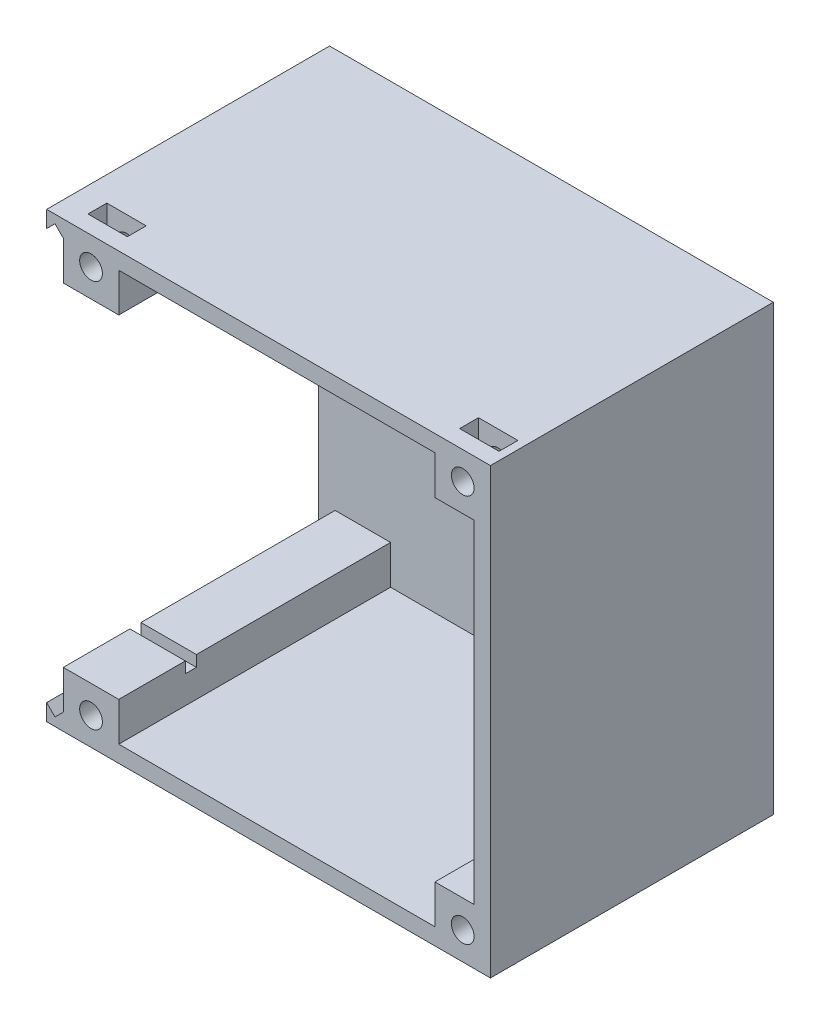
from build123d import *

# Parameters (mm, degrees)
ESQUISSE3_W             = 80
ESQUISSE3_H             = 80
BOSS_EXTRU_1_DEPTH      = 2
BOSS_EXTRU_2_DEPTH      = 49
ESQUISSE7_R             = 2.05
ENL_V_MAT_EXTRU_1_DEPTH = 30
ESQUISSE8_W             = 7.1
ESQUISSE8_H             = 3.4
ENL_V_MAT_EXTRU_2_DEPTH = 9
ESQUISSE9_W             = 7.1
ESQUISSE9_H             = 3.4
ENL_V_MAT_EXTRU_3_DEPTH = 9
ESQUISSE10_W            = 2
ESQUISSE10_H            = 2
ENL_V_MAT_EXTRU_4_DEPTH = 74


with BuildPart() as part:
    # Esquisse3 → Boss.-Extru.1 (new body)
    with BuildSketch(Plane.XY):
        with Locations((40, 40)):
            Rectangle(ESQUISSE3_W, ESQUISSE3_H)
    extrude(amount=BOSS_EXTRU_1_DEPTH)

    # Esquisse6 → Boss.-Extru.2 (add)
    with BuildSketch(Plane.XY.offset(2)):
        Polygon((0, 0), (80, 0), (80, 80), (0, 80), (0, 77), (1.5, 78.5), (3, 77), (3, 70), (13, 70), (13, 77), (70, 77), (70, 70), (77, 70), (77, 10), (70, 10), (70, 3), (13, 3), (13, 10), (3, 10), (3, 3), (1.5, 1.5), (0, 3), align=None)
    extrude(amount=BOSS_EXTRU_2_DEPTH)

    # Esquisse7 → Enlèv. mat.-Extru.1 (cut)
    with BuildSketch(Plane.XY.offset(51)):
        with Locations((8, 75)):
            Circle(ESQUISSE7_R)
        with Locations((8, 5)):
            Circle(ESQUISSE7_R)
        with Locations((75, 5)):
            Circle(ESQUISSE7_R)
        with Locations((75, 75)):
            Circle(ESQUISSE7_R)
    extrude(amount=-ENL_V_MAT_EXTRU_1_DEPTH, mode=Mode.SUBTRACT)

    # Esquisse8 → Enlèv. mat.-Extru.2 (cut)
    with BuildSketch(Plane.XZ):
        with Locations((8, 46.3)):
            Rectangle(ESQUISSE8_W, ESQUISSE8_H)
        with Locations((75, 46.3)):
            Rectangle(ESQUISSE8_W, ESQUISSE8_H)
    extrude(amount=-ENL_V_MAT_EXTRU_2_DEPTH, mode=Mode.SUBTRACT)

    # Esquisse9 → Enlèv. mat.-Extru.3 (cut)
    with BuildSketch(Plane(origin=(0, 80, 0), x_dir=(1, 0, 0), z_dir=(0, 1, 0))):
        with Locations((75, -46.3)):
            Rectangle(ESQUISSE9_W, ESQUISSE9_H)
        with Locations((8, -46.3)):
            Rectangle(ESQUISSE9_W, ESQUISSE9_H)
    extrude(amount=-ENL_V_MAT_EXTRU_3_DEPTH, mode=Mode.SUBTRACT)

    # Esquisse10 → Enlèv. mat.-Extru.4 (cut)
    with BuildSketch(Plane.ZY.offset(-3)):
        with Locations((38, 71)):
            Rectangle(ESQUISSE10_W, ESQUISSE10_H)
        with Locations((38, 9)):
            Rectangle(ESQUISSE10_W, ESQUISSE10_H)
    extrude(amount=-ENL_V_MAT_EXTRU_4_DEPTH, mode=Mode.SUBTRACT)


solid = part.part
